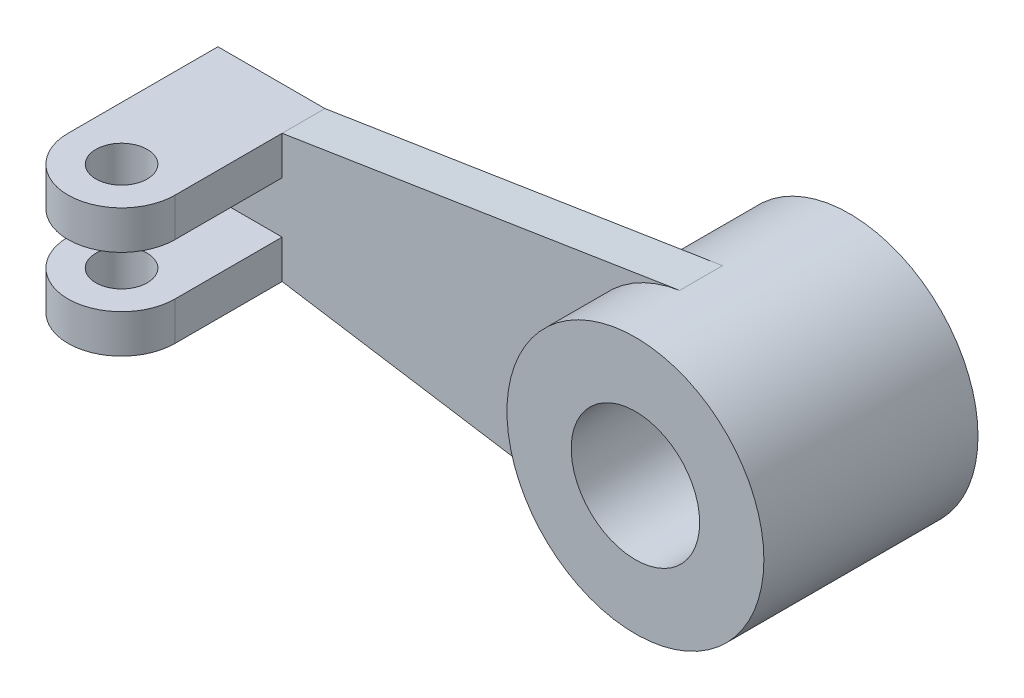
from build123d import *

# Parameters (mm, degrees)
SKETCH1_R           = 30
BOSS_EXTRUDE1_DEPTH = 25
SKETCH2_R           = 15
CUT_EXTRUDE1_DEPTH  = 50
BOSS_EXTRUDE3_DEPTH = 10
SKETCH8_R           = 6
BOSS_EXTRUDE4_DEPTH = 9


with BuildPart() as part:
    # Sketch1 → Boss-Extrude1 (new body, symmetric)
    with BuildSketch(Plane.XY):
        Circle(SKETCH1_R)
    extrude(amount=BOSS_EXTRUDE1_DEPTH, both=True)

    # Sketch2 → Cut-Extrude1 (cut)
    with BuildSketch(Plane.XY.offset(25)):
        Circle(SKETCH2_R)
    extrude(amount=-CUT_EXTRUDE1_DEPTH, mode=Mode.SUBTRACT)

    # Sketch6 → Boss-Extrude3 (add)
    with BuildSketch(Plane.XY):
        with BuildLine():
            Line((-4.671688756, 29.634023084), (-97.5, 15))
            Line((-97.5, 15), (-122.5, 15))
            Line((-122.5, 15), (-122.5, -15))
            Line((-122.5, -15), (-97.5, -15))
            Line((-97.5, -15), (-4.671688756, -29.634023084))
            ThreePointArc((-4.671688756, -29.634023084), (-30, 0), (-4.671688756, 29.634023084))
        make_face()
    extrude(amount=BOSS_EXTRUDE3_DEPTH)

    # Sketch8 → Boss-Extrude4 (add)
    with BuildSketch(Plane.XZ.offset(15)):
        with BuildLine():
            Line((-122.5, 10), (-122.5, 35))
            ThreePointArc((-122.5, 35), (-110, 47.5), (-97.5, 35))
            Line((-97.5, 35), (-97.5, 10))
            Line((-97.5, 10), (-122.5, 10))
        make_face()
        with Locations((-110, 35)):
            Circle(SKETCH8_R, mode=Mode.SUBTRACT)
    boss_extrude4 = extrude(amount=-BOSS_EXTRUDE4_DEPTH)

    # Mirror1: Boss-Extrude4 across plane
    add(boss_extrude4.mirror(Plane.ZX))


solid = part.part
